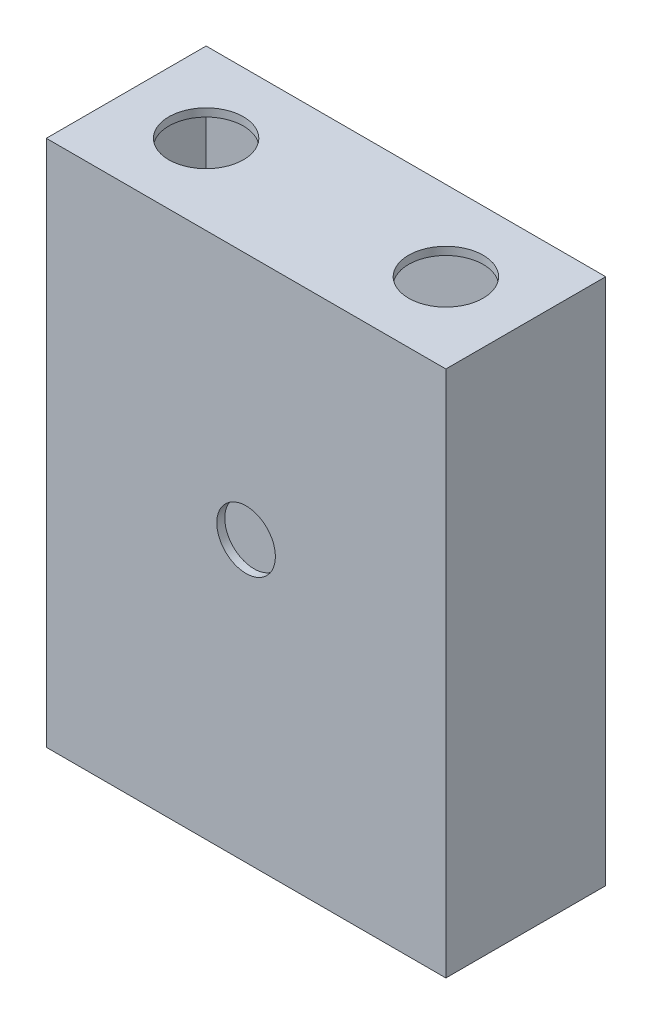
from build123d import *

# Parameters (mm, degrees)
CROQUIS1_W              = 240
CROQUIS1_H              = 60
CROQUIS1_R              = 14
SALIENTE_EXTRUIR1_DEPTH = 3
CROQUIS4_W              = 90
CROQUIS4_H              = 60
CORTAR_EXTRUIR2_DEPTH   = 5
CROQUIS2_W              = 150
CROQUIS2_H              = 60
CROQUIS2_W_2            = 144
CROQUIS2_H_2            = 54
SALIENTE_EXTRUIR2_DEPTH = 195
CROQUIS5_R              = 11
CORTAR_EXTRUIR3_DEPTH   = 5


with BuildPart() as part:
    # Croquis1 → Saliente-Extruir1 (new body)
    with BuildSketch(Plane(origin=(0, 0, 0), x_dir=(1, 0, 0), z_dir=(0, 1, 0))):
        Rectangle(CROQUIS1_W, CROQUIS1_H)
        Circle(CROQUIS1_R, mode=Mode.SUBTRACT)
        with Locations((-90, 0)):
            Circle(CROQUIS1_R, mode=Mode.SUBTRACT)
    extrude(amount=SALIENTE_EXTRUIR1_DEPTH)

    # Croquis4 → Cortar-Extruir2 (cut)
    with BuildSketch(Plane(origin=(0, 3, 0), x_dir=(1, 0, 0), z_dir=(0, 1, 0))):
        with Locations((75, 0)):
            Rectangle(CROQUIS4_W, CROQUIS4_H)
    extrude(amount=-CORTAR_EXTRUIR2_DEPTH, mode=Mode.SUBTRACT)

    # Croquis2 → Saliente-Extruir2 (add)
    with BuildSketch(Plane.XZ):
        with Locations((-45, 0)):
            Rectangle(CROQUIS2_W, CROQUIS2_H)
        with Locations((-45, 0)):
            Rectangle(CROQUIS2_W_2, CROQUIS2_H_2, mode=Mode.SUBTRACT)
    extrude(amount=SALIENTE_EXTRUIR2_DEPTH)

    # Croquis5 → Cortar-Extruir3 (cut)
    with BuildSketch(Plane.XY.offset(30)):
        with Locations((-45, -90)):
            Circle(CROQUIS5_R)
    extrude(amount=-CORTAR_EXTRUIR3_DEPTH, mode=Mode.SUBTRACT)


solid = part.part
